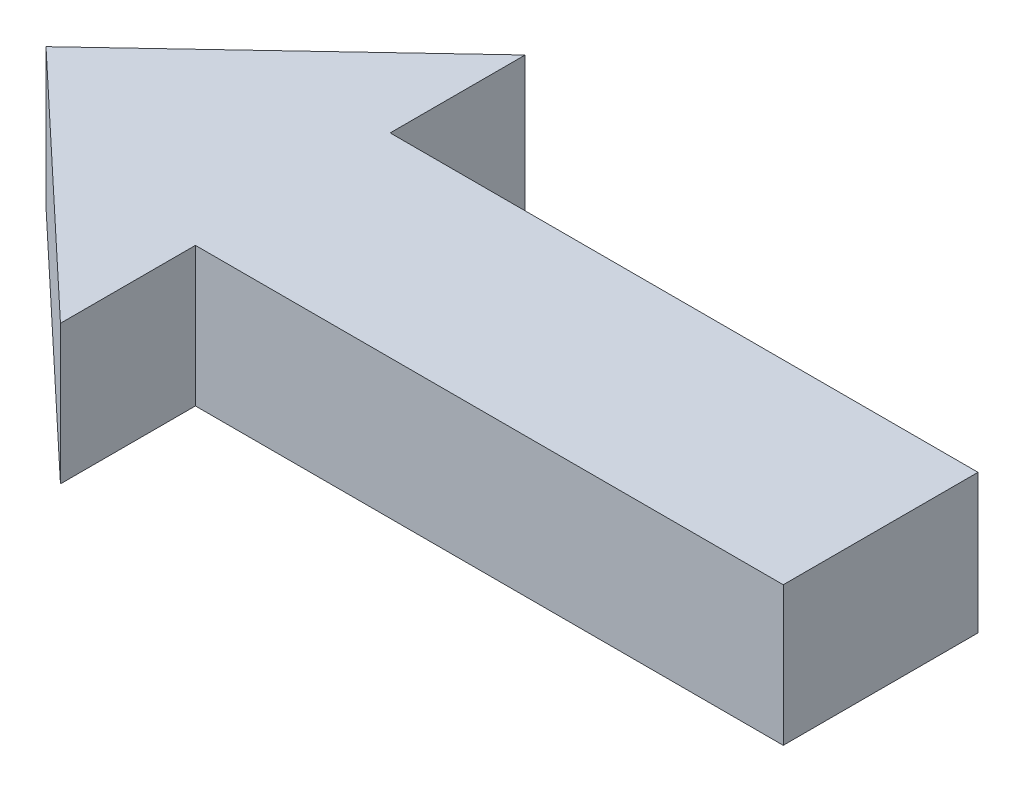
from build123d import *

# Parameters (mm, degrees)
BOSS_EXTRUDE1_DEPTH = 50


with BuildPart() as part:
    # Sketch1 → Boss-Extrude1 (new body)
    with BuildSketch(Plane(origin=(0, 0, 0), x_dir=(1, 0, 0), z_dir=(0, 1, 0))):
        Polygon((-211.293634497, 0), (-211.293634497, 48.511293634), (-300, -35), (-211.293634497, -118.511293634), (-211.293634497, -70), (0, -70), (0, 0), align=None)
    extrude(amount=BOSS_EXTRUDE1_DEPTH)


solid = part.part
